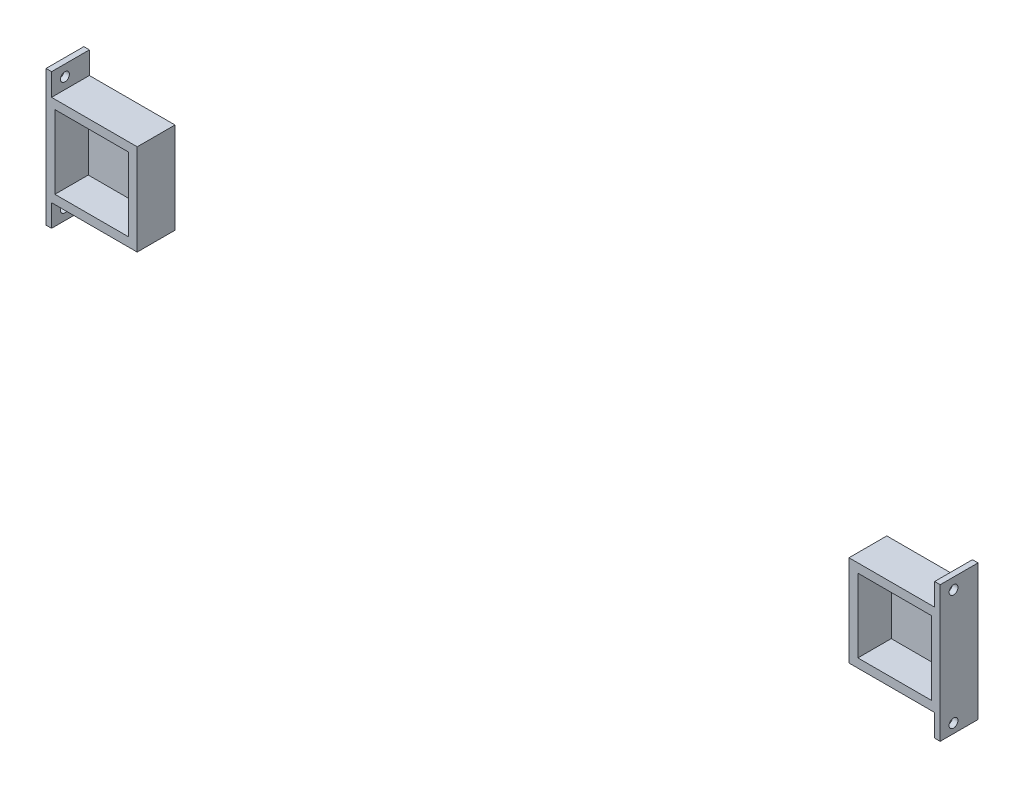
from build123d import *

# Parameters (mm, degrees)
SKETCH1_W             = 52.07
SKETCH1_H             = 52.07
SKETCH1_W_2           = 41.91
SKETCH1_H_2           = 41.91
BOSS_EXTRUDE1_DEPTH   = 19.05
BOSS_EXTRUDE1_2_DEPTH = 19.05
SKETCH3_W             = 52.07
SKETCH3_H             = 52.07
BOSS_EXTRUDE6_DEPTH   = 2.54
SKETCH4_W             = 21.59
SKETCH4_H             = 12.7
SKETCH4_R             = 2.54
BOSS_EXTRUDE7_DEPTH   = 3.175
SKETCH5_W             = 21.59
SKETCH5_H             = 12.7
SKETCH5_R             = 2.54
BOSS_EXTRUDE8_DEPTH   = 3.175


with BuildPart() as part:
    # Sketch1 → Boss-Extrude1 (new body)
    with BuildSketch(Plane.XY):
        with Locations((20.955, 20.955)):
            Rectangle(SKETCH1_W, SKETCH1_H)
        with Locations((20.955, 20.955)):
            Rectangle(SKETCH1_W_2, SKETCH1_H_2, mode=Mode.SUBTRACT)
    extrude(amount=BOSS_EXTRUDE1_DEPTH)



with BuildPart() as body_2:
    # Sketch1 → Boss-Extrude1 2 (new body)
    with BuildSketch(Plane.XY):
        with Locations((479.425, 20.955)):
            Rectangle(SKETCH1_W, SKETCH1_H)
        with Locations((479.425, 20.955)):
            Rectangle(SKETCH1_W_2, SKETCH1_H_2, mode=Mode.SUBTRACT)
    extrude(amount=BOSS_EXTRUDE1_2_DEPTH)


with BuildPart() as part_1:
    add(part.part)

    add(body_2.part)  # Boss-Extrude6 merges body 2
    # Sketch3 → Boss-Extrude6 (add)
    with BuildSketch(Plane(origin=(0, 0, 0), x_dir=(-1, 0, 0), z_dir=(0, 0, -1))):
        with Locations((-20.955, 20.955)):
            Rectangle(SKETCH3_W, SKETCH3_H)
        with Locations((-479.425, 20.955)):
            Rectangle(SKETCH3_W, SKETCH3_H)
    extrude(amount=BOSS_EXTRUDE6_DEPTH)

    # Sketch4 → Boss-Extrude7 (add)
    with BuildSketch(Plane.ZY.offset(5.08)):
        with Locations((8.255, -11.43)):
            Rectangle(SKETCH4_W, SKETCH4_H)
        with Locations((11.43, -11.43)):
            Circle(SKETCH4_R, mode=Mode.SUBTRACT)
        with Locations((8.255, 53.34)):
            Rectangle(SKETCH4_W, SKETCH4_H)
        with Locations((11.43, 53.34)):
            Circle(SKETCH4_R, mode=Mode.SUBTRACT)
    extrude(amount=-BOSS_EXTRUDE7_DEPTH)

    # Sketch5 → Boss-Extrude8 (add)
    with BuildSketch(Plane(origin=(505.46, 0, 0), x_dir=(0, 0, -1), z_dir=(1, 0, 0))):
        with Locations((-8.255, -11.43)):
            Rectangle(SKETCH5_W, SKETCH5_H)
        with Locations((-11.43, -12.509213566)):
            Circle(SKETCH5_R, mode=Mode.SUBTRACT)
        with Locations((-8.255, 53.34)):
            Rectangle(SKETCH5_W, SKETCH5_H)
        with Locations((-11.43, 53.34)):
            Circle(SKETCH5_R, mode=Mode.SUBTRACT)
    extrude(amount=-BOSS_EXTRUDE8_DEPTH)


solid = part_1.part
